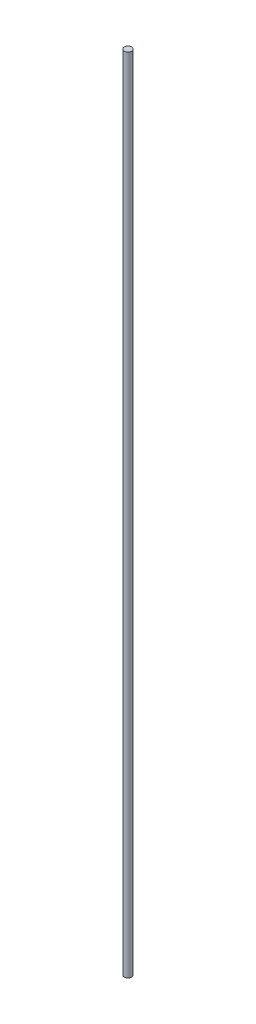
from build123d import *

# Parameters (mm, degrees)
SKETCH1_R           = 3.175
BOSS_EXTRUDE1_DEPTH = 342.9


with BuildPart() as part:
    # Sketch1 → Boss-Extrude1 (new body, symmetric)
    with BuildSketch(Plane(origin=(0, 0, 0), x_dir=(1, 0, 0), z_dir=(0, 1, 0))):
        Circle(SKETCH1_R)
    extrude(amount=BOSS_EXTRUDE1_DEPTH, both=True)


solid = part.part
